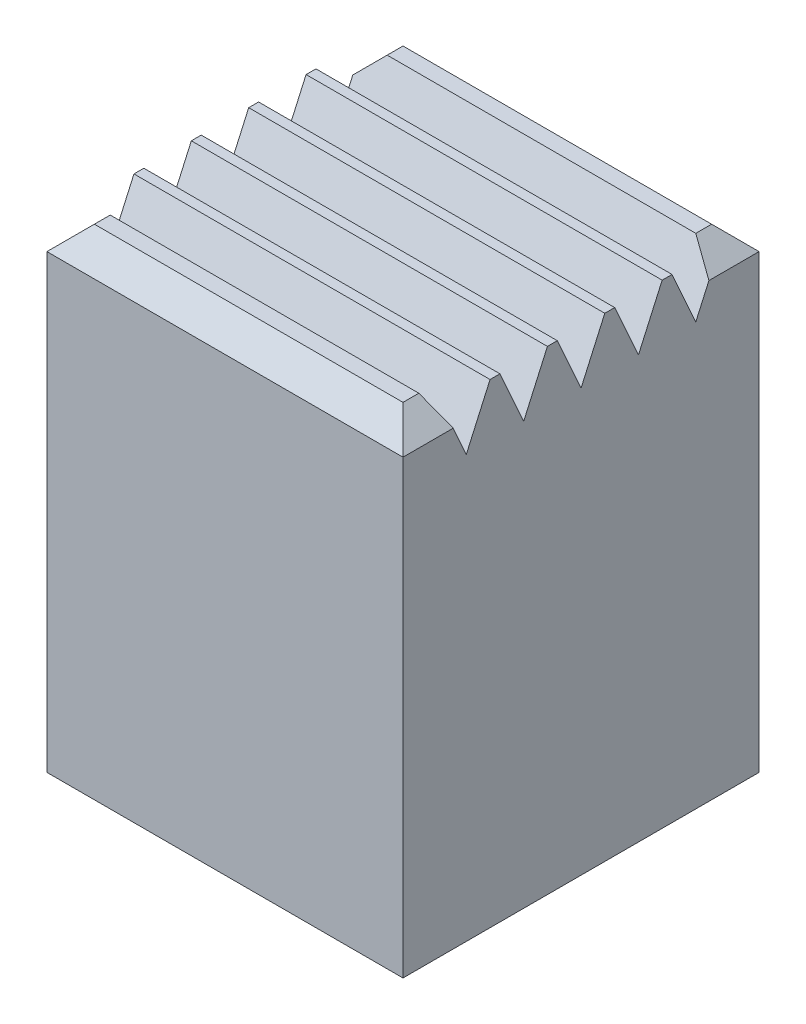
from build123d import *

# Parameters (mm, degrees)
SKETCH1_W           = 4.5
SKETCH1_H           = 4.5
BOSS_EXTRUDE1_DEPTH = 6
SKETCH2_W           = 3.2
SKETCH2_H           = 3.2
CUT_EXTRUDE1_DEPTH  = 4.9
CUT_EXTRUDE2_DEPTH  = 4.5
LPATTERN1_COUNT     = 5
LPATTERN1_PITCH     = 0.725
CHAMFER1_SIZE       = 0.3


with BuildPart() as part:
    # Sketch1 → Boss-Extrude1 (new body)
    with BuildSketch(Plane(origin=(0, 0, 0), x_dir=(1, 0, 0), z_dir=(0, 1, 0))):
        with Locations((2.25, 2.25)):
            Rectangle(SKETCH1_W, SKETCH1_H)
    extrude(amount=BOSS_EXTRUDE1_DEPTH)

    # Sketch2 → Cut-Extrude1 (cut)
    with BuildSketch(Plane.XZ):
        with Locations((2.25, -2.25)):
            Rectangle(SKETCH2_W, SKETCH2_H)
    extrude(amount=-CUT_EXTRUDE1_DEPTH, mode=Mode.SUBTRACT)

    # Sketch3 → Cut-Extrude2 (cut)
    with BuildSketch(Plane.ZY):
        Polygon((-4, 6), (-3.7, 5.33), (-3.4, 6), align=None)
    cut_extrude2 = extrude(amount=-CUT_EXTRUDE2_DEPTH, mode=Mode.SUBTRACT)

    # LPattern1: Cut-Extrude2 ×5
    with Locations(*[(0, 0, i * LPATTERN1_PITCH) for i in range(1, LPATTERN1_COUNT)]):
        add(cut_extrude2, mode=Mode.SUBTRACT)

    # Chamfer1
    chamfer1_edges = [part.edges().sort_by_distance(p)[0] for p in [
        (4.5, 6, -0.25),
        (2.25, 6, -4.5),
        (4.5, 6, -4.25),
        (0, 6, -0.25),
        (0, 6, -4.25),
        (2.25, 6, 0),
    ]]
    chamfer(chamfer1_edges, length=CHAMFER1_SIZE)


solid = part.part
